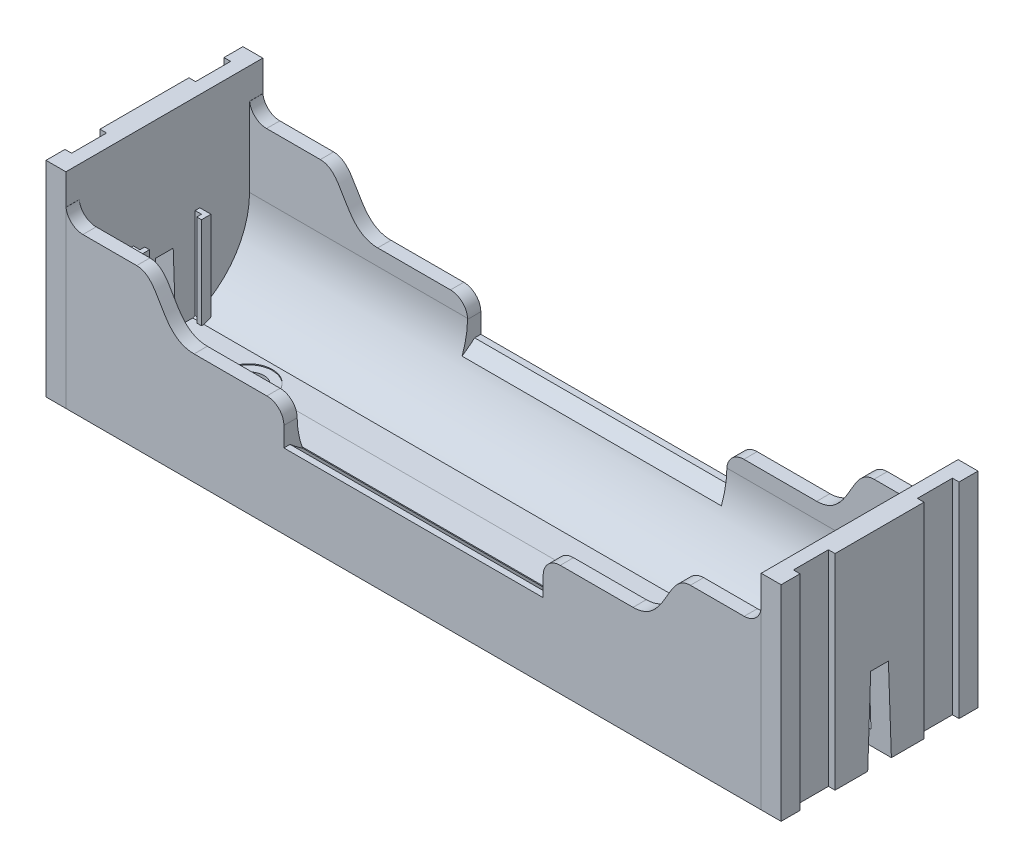
from build123d import *

# Parameters (mm, degrees)
EXTRUDE_1_DEPTH     = 10.4
CUT_EXTRUDE_1_DEPTH = 74.4500001
CUT_EXTRUDE_START   = -23.03
SKETCH_3_R          = 15
CUT_EXTRUDE_2_DEPTH = 27.39
EXTRUDE_8_DEPTH     = 21.65
EXTRUDE_9_DEPTH     = 11.28
SKETCH_16_W         = 3.39091882
SKETCH_16_H         = 2.5
CUT_EXTRUDE_5_DEPTH = 9
CUT_EXTRUDE_5_TAPER = 2
SKETCH_18_R         = 1.6
CUT_EXTRUDE_6_DEPTH = 9
SKETCH_21_R         = 2.5
CUT_EXTRUDE_9_DEPTH = 0.1


with BuildPart() as part:
    # Sketch 1 → Extrude 1 (new body)
    with BuildSketch(Plane.XY):
        with BuildLine():
            Line((-36.725, 0), (36.725, 0))
            Line((36.725, 0), (36.725, 18.61))
            ThreePointArc((36.725, 18.61), (36.197792206, 17.337207794), (34.925, 16.81))
            Line((34.925, 16.81), (29.245, 16.81))
            add(Edge.make_bspline(
                [(29.245, 16.81), (26.615660483, 16.785816988), (26.812848665, 11.78956424), (23.185, 11.76)],
                knots=[0, 0, 0, 0, 1, 1, 1, 1], degree=3))
            Line((23.185, 11.76), (15.495, 11.76))
            ThreePointArc((15.495, 11.76), (14.222207794, 11.232792206), (13.695, 9.96))
            Line((13.695, 9.96), (13.695, 7.9))
            Line((13.695, 7.9), (-13.695, 7.9))
            Line((-13.695, 7.9), (-13.695, 9.96))
            ThreePointArc((-13.695, 9.96), (-14.222207794, 11.232792206), (-15.495, 11.76))
            Line((-15.495, 11.76), (-23.185, 11.76))
            add(Edge.make_bspline(
                [(-29.245, 16.81), (-26.615660483, 16.785816988), (-26.812848665, 11.78956424), (-23.185, 11.76)],
                knots=[0, 0, 0, 0, 1, 1, 1, 1], degree=3))
            Line((-29.245, 16.81), (-34.925, 16.81))
            ThreePointArc((-34.925, 16.81), (-36.197792206, 17.337207794), (-36.725, 18.61))
            Line((-36.725, 18.61), (-36.725, 0))
        make_face()
    extrude(amount=-EXTRUDE_1_DEPTH)

    # Sketch 2 → Cut-Extrude 1 (cut, through all)
    with BuildSketch(Plane.ZY.offset(36.725)):
        with BuildLine():
            Line((0, 1.574923167), (-3, 1.574923167))
            ThreePointArc((-3, 1.574923167), (-7.348469228, 4.864052118), (-9, 10.060204541))
            Line((-9, 10.060204541), (-9, 18.405231898))
            Line((-9, 18.405231898), (-10.765680148, 18.405231898))
            Line((-10.765680148, 18.405231898), (-10.765680148, 19.973545767))
            Line((-10.765680148, 19.973545767), (0, 19.973545767))
            Line((0, 19.973545767), (0, 1.574923167))
        make_face()
    extrude(amount=-CUT_EXTRUDE_1_DEPTH, mode=Mode.SUBTRACT)

    # Sketch 3 → Cut-Extrude 2 (cut)
    with BuildSketch(Plane.ZY.offset(36.725).offset(CUT_EXTRUDE_START)):
        with Locations((0, 19.3)):
            Circle(SKETCH_3_R)
    extrude(amount=-CUT_EXTRUDE_2_DEPTH, mode=Mode.SUBTRACT)


with BuildPart() as body_2:
    # Mirror 6: mirrored copy
    add(part.part.mirror(Plane(origin=(-34.925, 18.61, 0), x_dir=(1, 0, 0), z_dir=(0, 0, 1))))


with BuildPart() as part_1:
    add(part.part)

    # Sketch 5 → Extrude 8 (add)
    with BuildSketch(Plane.XZ):
        Polygon((36.725, 10.4), (36.725, -10.4), (38.825, -10.4), (38.825, -8.4), (38.125, -8.4), (38.125, -4.7), (38.825, -4.7), (38.825, 4.7), (38.125, 4.7), (38.125, 8.4), (38.825, 8.4), (38.825, 10.4), align=None)
        Polygon((-38.125, 8.4), (-38.825, 8.4), (-38.825, 10.4), (-36.725, 10.4), (-36.725, -10.4), (-38.125, -10.4), (-38.825, -10.4), (-38.825, -8.4), (-38.125, -8.4), (-38.125, -4.7), (-38.825, -4.7), (-38.825, 4.7), (-38.125, 4.7), align=None)
    extrude(amount=-EXTRUDE_8_DEPTH)

    # Sketch 4 → Extrude 9 (add)
    with BuildSketch(Plane.XZ):
        Polygon((-36.05, -3.25), (-37.25, -3.25), (-37.25, -3.75), (-35.55, -3.75), (-35.55, -2.75), (-36.05, -2.75), align=None)
        Polygon((-36.05, 3.25), (-37.25, 3.25), (-37.25, 3.75), (-35.55, 3.75), (-35.55, 2.75), (-36.05, 2.75), align=None)
        Polygon((36.05, 2.75), (36.05, 3.25), (37.25, 3.25), (37.25, 3.75), (35.55, 3.75), (35.55, 2.75), align=None)
        Polygon((37.25, -3.75), (37.25, -3.25), (36.05, -3.25), (36.05, -2.75), (35.55, -2.75), (35.55, -3.75), align=None)
    extrude(amount=-EXTRUDE_9_DEPTH)


with BuildPart() as cut_extrude_5_tool:
    # Sketch 16 → Cut-Extrude 5 (new body)
    with BuildSketch(Plane.XZ):
        with Locations((-37.74545941, 0)):
            Rectangle(SKETCH_16_W, SKETCH_16_H)
        with Locations((37.74545941, 0)):
            Rectangle(SKETCH_16_W, SKETCH_16_H)
    extrude(amount=-CUT_EXTRUDE_5_DEPTH, taper=CUT_EXTRUDE_5_TAPER)


with BuildPart() as part_2:
    add(part_1.part)

    # Cut-Extrude 5: cut by cut_extrude_5_tool
    add(cut_extrude_5_tool.part, mode=Mode.SUBTRACT)


with BuildPart() as body_2_1:
    add(body_2.part)

    # Cut-Extrude 5: cut by cut_extrude_5_tool
    add(cut_extrude_5_tool.part, mode=Mode.SUBTRACT)


with BuildPart() as cut_extrude_6_tool:
    # Sketch 18 → Cut-Extrude 6 (new body)
    with BuildSketch(Plane.XZ):
        with Locations((-27.81, 0)):
            Circle(SKETCH_18_R)
        with Locations((27.81, 0)):
            Circle(SKETCH_18_R)
    extrude(amount=-CUT_EXTRUDE_6_DEPTH)


with BuildPart() as part_3:
    add(part_2.part)

    # Cut-Extrude 6: cut by cut_extrude_6_tool
    add(cut_extrude_6_tool.part, mode=Mode.SUBTRACT)


with BuildPart() as body_2_2:
    add(body_2_1.part)

    # Cut-Extrude 6: cut by cut_extrude_6_tool
    add(cut_extrude_6_tool.part, mode=Mode.SUBTRACT)


with BuildPart() as cut_extrude_9_tool:
    # Sketch 21 → Cut-Extrude 9 (new body)
    with BuildSketch(Plane(origin=(0, 1.574923167, 0), x_dir=(1, 0, 0), z_dir=(0, 1, 0))):
        with Locations((27.81, 0)):
            Circle(SKETCH_21_R)
        with Locations((-27.81, 0)):
            Circle(SKETCH_21_R)
    extrude(amount=-CUT_EXTRUDE_9_DEPTH)


with BuildPart() as part_4:
    add(part_3.part)

    # Cut-Extrude 9: cut by cut_extrude_9_tool
    add(cut_extrude_9_tool.part, mode=Mode.SUBTRACT)


with BuildPart() as body_2_3:
    add(body_2_2.part)

    # Cut-Extrude 9: cut by cut_extrude_9_tool
    add(cut_extrude_9_tool.part, mode=Mode.SUBTRACT)


solid = Compound([part_4.part, body_2_3.part])
